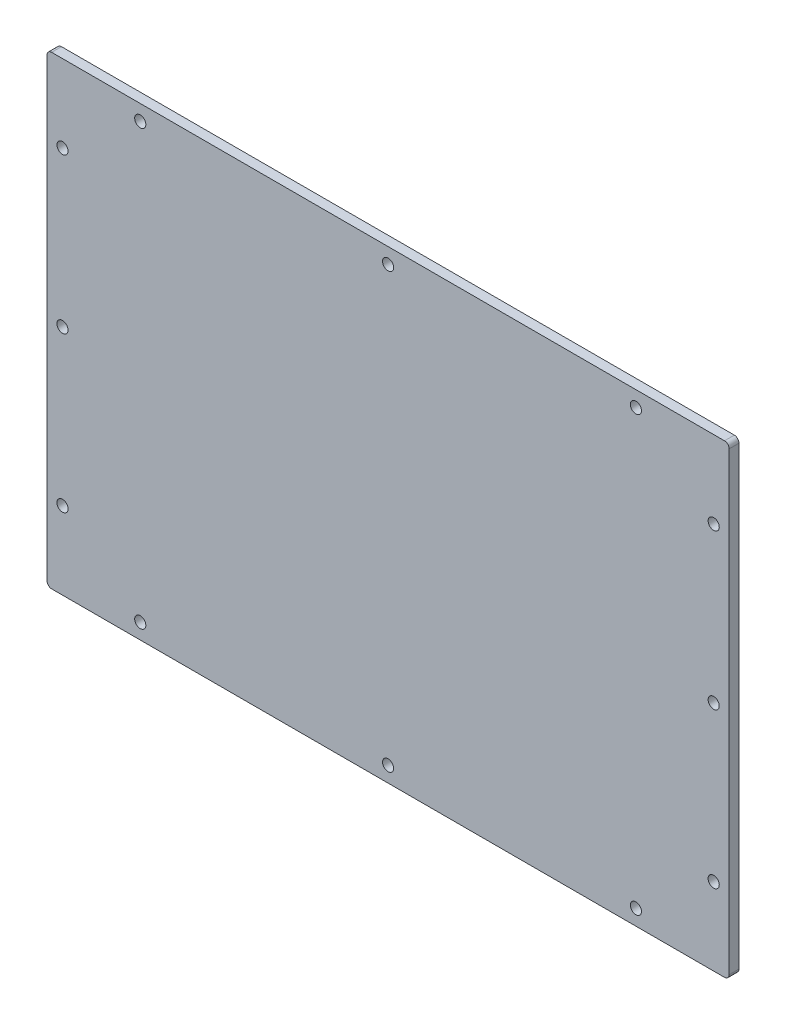
from build123d import *

# Parameters (mm, degrees)
SKETCH1_W            = 220.21
SKETCH1_H            = 150
BOSS_EXTRUDE1_DEPTH  = 3.175
M3_CLEARANCE_HOLE1_D = 3.6
SKETCH4_W            = 10
SKETCH4_H            = 10
BOSS_EXTRUDE2_DEPTH  = 3.175
FILLET2_R            = 1.5


with BuildPart() as part:
    # Sketch1 → Boss-Extrude1 (new body)
    with BuildSketch(Plane.XY):
        Rectangle(SKETCH1_W, SKETCH1_H)
    extrude(amount=BOSS_EXTRUDE1_DEPTH)

    # M3 Clearance Hole1 (through all)
    with Locations(Plane.XY.offset(3.175)):
        with Locations((0, 0), (-80, 70), (80, 70), (0, 70), (-105.105, 50), (-105.105, 0), (-105.105, -50), (-80, -70), (0, -70), (80, -70), (105.105, -50), (105.105, 0), (105.105, 50)):
            Hole(M3_CLEARANCE_HOLE1_D / 2)

    # Sketch4 → Boss-Extrude2 (add, through all)
    with BuildSketch(Plane.XY.offset(3.175)):
        Rectangle(SKETCH4_W, SKETCH4_H)
    extrude(amount=-BOSS_EXTRUDE2_DEPTH)

    # Fillet2
    fillet2_edges = [part.edges().sort_by_distance(p)[0] for p in [
        (-110.105, -75, 1.5875),
        (-110.105, 75, 1.5875),
        (110.105, 75, 1.5875),
        (110.105, -75, 1.5875),
    ]]
    fillet(fillet2_edges, radius=FILLET2_R)


solid = part.part
